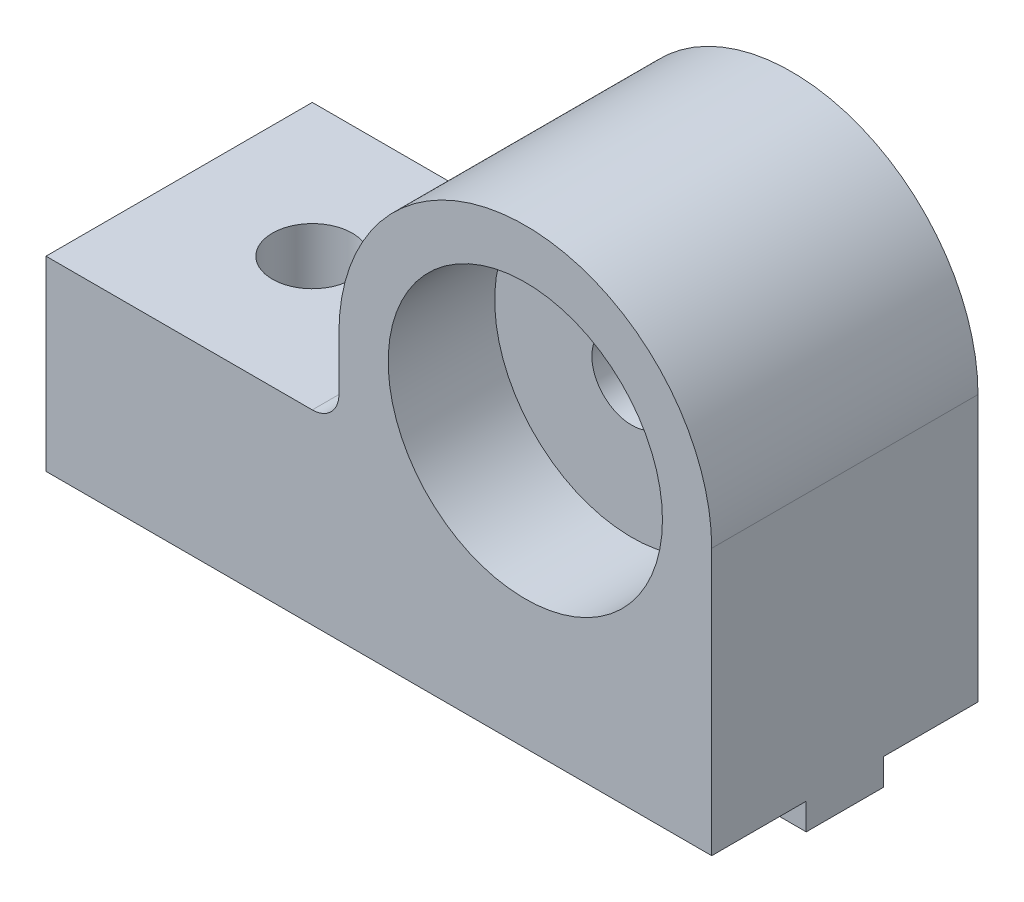
from build123d import *

# Parameters (mm, degrees)
SKETCH1_R              = 1.5
MAIN_DEPTH             = 5
SKETCH3_W              = 2.9
SKETCH3_H              = 1
MAKERBEAMRAIL_DEPTH    = 25
SKETCH2_R              = 1.5
MAKERBEAMFIXHOLE_DEPTH = 9
SKETCH4_R              = 5.15
ROLLINGHOLE_DEPTH      = 4
FILLET1_R              = 1


with BuildPart() as part:
    # Sketch1 → Main (new body, symmetric)
    with BuildSketch(Plane.XY):
        with BuildLine():
            Line((-18, 0), (7, 0))
            Line((7, 0), (7, 10))
            ThreePointArc((7, 10), (0, 17), (-7, 10))
            Line((-7, 10), (-7, 7))
            Line((-7, 7), (-18, 7))
            Line((-18, 7), (-18, 0))
        make_face()
        with Locations((0, 10)):
            Circle(SKETCH1_R, mode=Mode.SUBTRACT)
    extrude(amount=MAIN_DEPTH, both=True)

    # Sketch3 → MakerBeamRail (add)
    with BuildSketch(Plane.ZY.offset(18)):
        with Locations((0, -0.5)):
            Rectangle(SKETCH3_W, SKETCH3_H)
    extrude(amount=-MAKERBEAMRAIL_DEPTH)

    # Sketch2 → MakerBeamFixHole (cut, through all)
    with BuildSketch(Plane(origin=(0, 7, 0), x_dir=(1, 0, 0), z_dir=(0, 1, 0))):
        with Locations((-13, 0)):
            Circle(SKETCH2_R)
    extrude(amount=-MAKERBEAMFIXHOLE_DEPTH, mode=Mode.SUBTRACT)

    # Sketch4 → RollingHole (cut)
    with BuildSketch(Plane.XY.offset(5)):
        with Locations((0, 10)):
            Circle(SKETCH4_R)
    rollinghole = extrude(amount=-ROLLINGHOLE_DEPTH, mode=Mode.SUBTRACT)

    # MirrorRollingHole: RollingHole across plane
    add(rollinghole.mirror(Plane.XY), mode=Mode.SUBTRACT)

    # Fillet1
    fillet1_edges = [part.edges().sort_by_distance(p)[0] for p in [
        (-7, 7, 0),
    ]]
    fillet(fillet1_edges, radius=FILLET1_R)


solid = part.part
